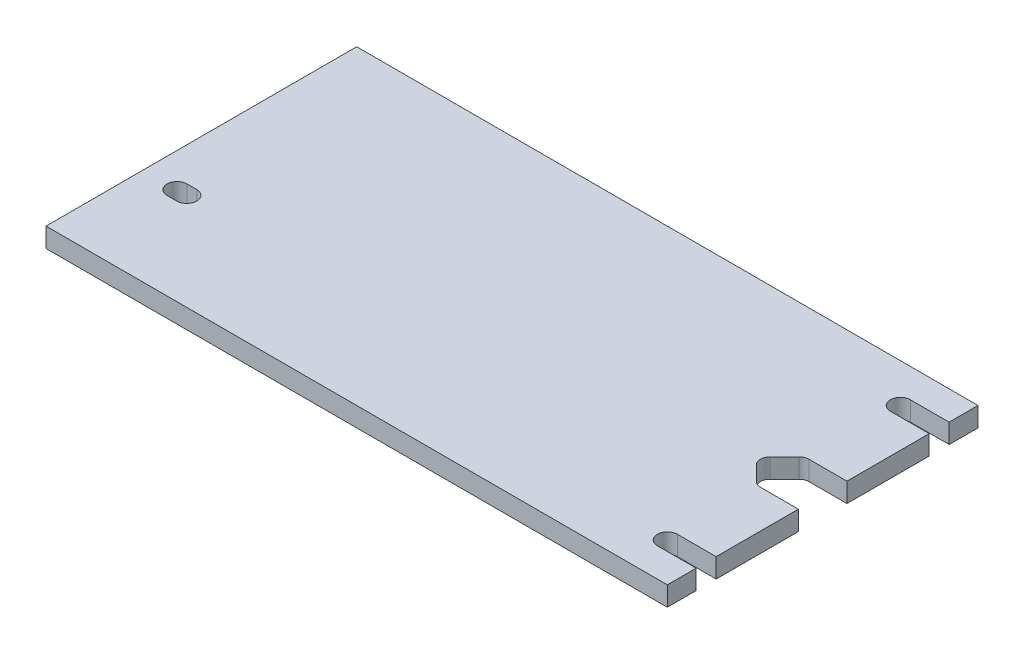
from build123d import *

# Parameters (mm, degrees)
BOSS_EXTRUDE1_DEPTH         = 6.35
F_1_4_CLEARANCE_HOLE1_D     = 6.5278
F_1_4_CLEARANCE_HOLE1_DEPTH = 6.35
CUT_EXTRUDE1_DEPTH          = 6.35
CUT_EXTRUDE2_START          = -6.35
CUT_EXTRUDE2_DEPTH          = 6.35


with BuildPart() as part:
    # Sketch1 → Boss-Extrude1 (new body)
    with BuildSketch(Plane(origin=(0, 0, 0), x_dir=(1, 0, 0), z_dir=(0, 1, 0))):
        with BuildLine():
            Line((-101.6, 50.8), (101.6, 50.8))
            Line((101.6, 50.8), (101.6, 7.9375))
            Line((101.6, 7.9375), (89.172371939, 7.9375))
            ThreePointArc((89.172371939, 7.9375), (87.957352042, 7.695817516), (86.927307909, 7.00756403))
            Line((86.927307909, 7.00756403), (82.164807909, 2.24506403))
            ThreePointArc((82.164807909, 2.24506403), (81.234871939, 0), (82.164807909, -2.24506403))
            Line((82.164807909, -2.24506403), (86.927307909, -7.00756403))
            ThreePointArc((86.927307909, -7.00756403), (87.957352042, -7.695817516), (89.172371939, -7.9375))
            Line((89.172371939, -7.9375), (101.6, -7.9375))
            Line((101.6, -7.9375), (101.6, -50.8))
            Line((101.6, -50.8), (-101.6, -50.8))
            Line((-101.6, -50.8), (-101.6, 50.8))
        make_face()
    extrude(amount=BOSS_EXTRUDE1_DEPTH)

    # 1/4 Clearance Hole1
    with Locations(Plane(origin=(0, 6.35, 0), x_dir=(-1, 0, 0), z_dir=(0, 1, 0))):
        with Locations((-88.9, 38.1), (-88.9, -38.1), (88.9, 19.05)):
            Hole(F_1_4_CLEARANCE_HOLE1_D / 2, depth=F_1_4_CLEARANCE_HOLE1_DEPTH)

    # Sketch4 → Cut-Extrude1 (cut)
    with BuildSketch(Plane(origin=(0, 6.35, 0), x_dir=(1, 0, 0), z_dir=(0, 1, 0))):
        with BuildLine():
            Line((88.9, 41.3639), (101.6, 41.3639))
            Line((101.6, 41.3639), (101.6, 34.8361))
            Line((101.6, 34.8361), (88.9, 34.8361))
            ThreePointArc((88.9, 34.8361), (85.6361, 38.1), (88.9, 41.3639))
        make_face()
    cut_extrude1 = extrude(amount=-CUT_EXTRUDE1_DEPTH, mode=Mode.SUBTRACT)

    # Mirror1: Cut-Extrude1 across plane
    add(cut_extrude1.mirror(Plane.XY), mode=Mode.SUBTRACT)

    # Sketch5 → Cut-Extrude2 (cut)
    with BuildSketch(Plane(origin=(0, 6.35, 0), x_dir=(1, 0, 0), z_dir=(0, 1, 0)).offset(CUT_EXTRUDE2_START)):
        with BuildLine():
            Line((-90.4875, -15.7861), (-87.3125, -15.7861))
            ThreePointArc((-87.3125, -15.7861), (-84.0486, -19.05), (-87.3125, -22.3139))
            Line((-87.3125, -22.3139), (-90.4875, -22.3139))
            ThreePointArc((-90.4875, -22.3139), (-93.7514, -19.05), (-90.4875, -15.7861))
        make_face()
    extrude(amount=CUT_EXTRUDE2_DEPTH, mode=Mode.SUBTRACT)


solid = part.part
